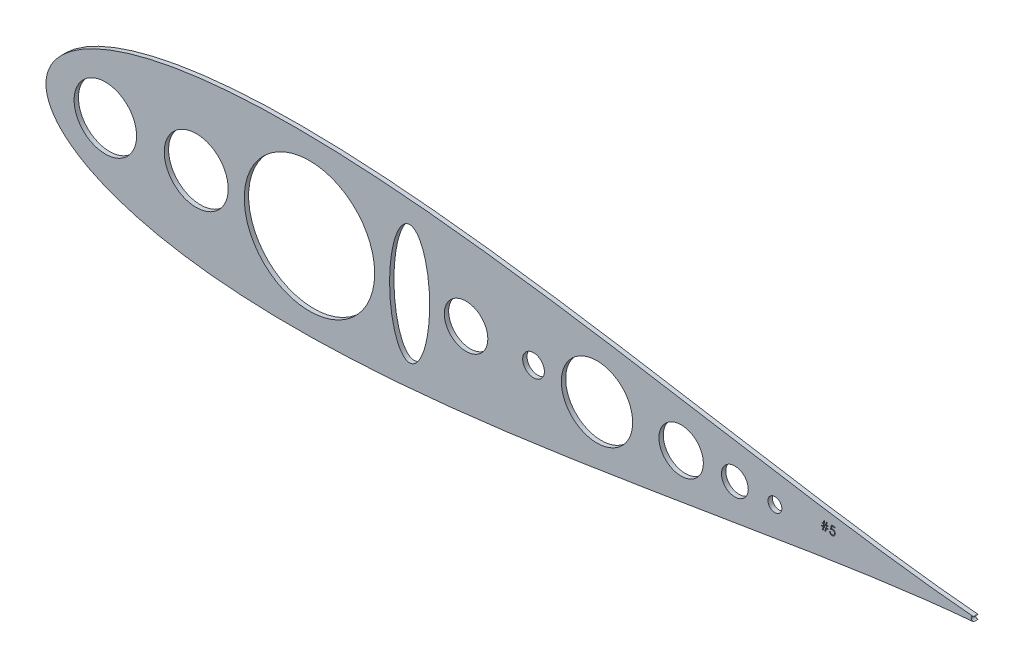
from build123d import *

# Parameters (mm, degrees)
SKETCH2_R           = 18.230878517
SKETCH2_R_2         = 4.037715602
SKETCH2_R_3         = 7.821827667
SKETCH2_R_4         = 12.957792122
SKETCH2_R_5         = 20.813476486
SKETCH2_R_6         = 6.35
SKETCH2_R_7         = 12.7
SKETCH2_R_8         = 38.053042593
SKETCH2_R_9         = 18.669
SKETCH2_RX          = 34.947973864
SKETCH2_RY          = 11.708179647
BOSS_EXTRUDE1_DEPTH = 2.54


with BuildPart() as part:
    # Sketch2 → Boss-Extrude1 (new body)
    with BuildSketch(Plane.XY):
        with BuildLine():
            ThreePointArc((823.421189551, 522.33997147), (821.998097763, 521.109243266), (823.419197676, 519.876215617))
            ThreePointArc((823.419197676, 519.876215617), (823.21960738, 519.810273255), (823.012147201, 519.776436063))
            add(Edge.make_bspline(
                [(823.012147201, 522.440589928), (822.576448471, 522.476822469), (819.292931445, 522.753399073), (812.826446411, 523.351083584), (803.227904679, 524.349584583), (792.585752436, 525.574842202), (780.939994867, 527.03420159), (768.344964456, 528.729148634), (754.855128067, 530.655883322), (740.528901562, 532.804453244), (725.427121068, 535.159573872), (709.613054207, 537.700217018), (693.152054171, 540.400141328), (676.111369741, 543.228220161), (658.559927393, 546.148757256), (640.568215799, 549.122125908), (622.208169894, 552.105244697), (603.553110232, 555.052283691), (584.67770325, 557.91528213), (565.657958282, 560.644999757), (546.571218667, 563.191541558), (527.496180515, 565.505247095), (508.512905779, 567.53740425), (489.702834491, 569.241109422), (471.148776984, 570.57195173), (452.934912277, 571.48884347), (435.146769771, 571.95479317), (417.871200148, 571.937494433), (401.196404591, 571.409505282), (385.211936158, 570.350153322), (370.008960014, 568.744076909), (355.6803978, 566.584036436), (342.32179621, 563.869274185), (330.031975696, 560.608874259), (318.914834654, 556.82194507), (309.081277399, 552.54222879), (300.650720518, 547.826398394), (293.749112715, 542.770151991), (288.492669192, 537.538633824), (284.933972909, 532.40845142), (282.949544686, 527.780006902), (282.14819506, 524.067129748), (281.965680463, 521.108512998), (282.14819506, 518.149896248), (282.949544686, 514.437019094), (284.933972909, 509.808574576), (288.492669192, 504.678392172), (293.749112715, 499.446874005), (300.650720518, 494.390627603), (309.081277399, 489.674797206), (318.914834654, 485.395080927), (330.031975696, 481.608151737), (342.32179621, 478.347751812), (355.6803978, 475.632989561), (370.008960014, 473.472949087), (385.211936158, 471.866872675), (401.196404591, 470.807520714), (417.871200148, 470.279531563), (435.146769771, 470.262232827), (452.934912277, 470.728182527), (471.148776984, 471.645074266), (489.702834491, 472.975916574), (508.512905779, 474.679621746), (527.496180515, 476.711778902), (546.571218667, 479.025484439), (565.657958282, 481.57202624), (584.67770325, 484.301743866), (603.553110232, 487.164742305), (622.208169894, 490.111781299), (640.568215799, 493.094900089), (658.559927393, 496.068268741), (676.111369741, 498.988805836), (693.152054171, 501.816884668), (709.613054207, 504.516808978), (725.427121068, 507.057452124), (740.528901562, 509.412572753), (754.855128067, 511.561142674), (768.344964456, 513.487877362), (780.939994867, 515.182824406), (792.585752436, 516.642183794), (803.227904679, 517.867441413), (812.826446411, 518.865942413), (819.292931445, 519.463626923), (822.576448471, 519.740203527), (823.012147201, 519.776436063)],
                knots=[0.020157042, 0.020157042, 0.020157042, 0.020157042, 0.021270888, 0.028552555, 0.036780684, 0.045920102, 0.055931764, 0.066772884, 0.07839713, 0.090754827, 0.103793165, 0.117456432, 0.131686226, 0.146421738, 0.161599998, 0.177156133, 0.193023668, 0.209134786, 0.225420633, 0.241811602, 0.258237647, 0.274628557, 0.290914287, 0.307025229, 0.322892517, 0.338448342, 0.353626207, 0.368361232, 0.382590428, 0.396252961, 0.409290412, 0.42164701, 0.433269881, 0.444109249, 0.45411864, 0.463255055, 0.471479114, 0.478755289, 0.485052318, 0.490344026, 0.494609833, 0.497833231, 0.5, 0.502166769, 0.505390167, 0.509655974, 0.514947682, 0.521244711, 0.528520886, 0.536744945, 0.54588136, 0.555890751, 0.566730119, 0.57835299, 0.590709588, 0.603747039, 0.617409572, 0.631638768, 0.646373793, 0.661551658, 0.677107483, 0.692974771, 0.709085713, 0.725371443, 0.741762353, 0.758188398, 0.774579367, 0.790865214, 0.806976332, 0.822843867, 0.838400002, 0.853578262, 0.868313774, 0.882543568, 0.896206835, 0.909245173, 0.92160287, 0.933227116, 0.944068236, 0.954079898, 0.963219316, 0.971447445, 0.978729112, 0.979842958, 0.979842958, 0.979842958, 0.979842958], degree=3))
            ThreePointArc((823.012147201, 522.440589928), (823.220656864, 522.406495028), (823.421189551, 522.33997147))
        make_face()
        with Locations((316.649549722, 521.108512996)):
            Circle(SKETCH2_R, mode=Mode.SUBTRACT)
        with Locations((707.419787474, 521.108512996)):
            Circle(SKETCH2_R_2, mode=Mode.SUBTRACT)
        with Locations((684.057814925, 521.108512996)):
            Circle(SKETCH2_R_3, mode=Mode.SUBTRACT)
        with Locations((652.702073206, 521.108512996)):
            Circle(SKETCH2_R_4, mode=Mode.SUBTRACT)
        with Locations((603.597568947, 521.108512996)):
            Circle(SKETCH2_R_5, mode=Mode.SUBTRACT)
        with Locations((566.553892107, 521.108512996)):
            Circle(SKETCH2_R_6, mode=Mode.SUBTRACT)
        with Locations((527.183892107, 521.108512996)):
            Circle(SKETCH2_R_7, mode=Mode.SUBTRACT)
        with Locations((435.793825307, 521.108512996)):
            Circle(SKETCH2_R_8, mode=Mode.SUBTRACT)
        with Locations((369.703892107, 521.108512996)):
            Circle(SKETCH2_R_9, mode=Mode.SUBTRACT)
        with Locations(Location((494.242570629, 521.108512996), (0, 0, -90))):
            Ellipse(SKETCH2_RX, SKETCH2_RY, mode=Mode.SUBTRACT)
        Polygon((738.293466219, 524.339836845), (738.293466219, 524.01419582), (737.322648908, 524.01419582), (737.059083207, 522.255734282), (736.665261094, 522.255734282), (736.928826795, 524.01419582), (735.889828395, 524.01419582), (735.626262694, 522.255734282), (735.232440581, 522.255734282), (735.496006282, 524.01419582), (734.646286732, 524.01419582), (734.646286732, 524.339836845), (735.544852433, 524.339836845), (735.720902119, 525.512144534), (734.776543144, 525.512144534), (734.776543144, 525.837785559), (735.76974827, 525.837785559), (736.013979044, 527.465990684), (736.406783531, 527.465990684), (736.162552757, 525.837785559), (737.202568782, 525.837785559), (737.446799556, 527.465990684), (737.839604044, 527.465990684), (737.59537327, 525.837785559), (738.423722631, 525.837785559), (738.423722631, 525.512144534), (737.546527119, 525.512144534), (737.371495069, 524.339836845), align=None, mode=Mode.SUBTRACT)
        Polygon((742.461671345, 527.335734282), (742.461671345, 526.814708634), (740.733738657, 526.814708634), (740.459996669, 525.478562808), (740.621799556, 525.521303184), (740.775461408, 525.552849659), (740.920982244, 525.571166971), (741.058362056, 525.577272745), (741.228305958, 525.570149345), (741.391126471, 525.547761521), (741.545805958, 525.511126908), (741.693362056, 525.460245496), (741.832777119, 525.395117295), (741.964051157, 525.314724659), (742.088201795, 525.220085245), (742.205229044, 525.110181396), (742.31106237, 524.989083634), (742.402648908, 524.860862483), (742.481006282, 524.723482672), (742.544099232, 524.578979471), (742.593963008, 524.425317609), (742.62856237, 524.263514722), (742.649932569, 524.09357082), (742.657055958, 523.915485883), (742.652985445, 523.791335245), (742.642809169, 523.669219858), (742.624491858, 523.550157358), (742.599051157, 523.433130109), (742.566487056, 523.319155757), (742.526799556, 523.208234282), (742.478971031, 523.099348059), (742.425036732, 522.992497096), (742.364996669, 522.890734282), (742.298850832, 522.795077222), (742.228634483, 522.705525946), (742.153329996, 522.622080433), (742.071919744, 522.544740684), (741.985421345, 522.47350671), (741.894852433, 522.408378509), (741.798177757, 522.349356071), (741.697432569, 522.296439408), (741.592616858, 522.25166377), (741.48474827, 522.212993896), (741.372809169, 522.181447421), (741.256799556, 522.157024345), (741.13671942, 522.139724659), (741.012568782, 522.128530757), (740.885365257, 522.12547787), (740.733738657, 522.131583634), (740.58821782, 522.150918571), (740.448802757, 522.181447421), (740.315493458, 522.225205433), (740.188289933, 522.281174983), (740.067192182, 522.350373697), (739.951182569, 522.430766333), (739.842296345, 522.524388122), (739.741551157, 522.628186197), (739.65199987, 522.739107672), (739.57262487, 522.857152546), (739.503426157, 522.983338446), (739.445421345, 523.115630109), (739.398610445, 523.256062808), (739.361975832, 523.403618896), (739.335517496, 523.558298383), (739.791414933, 523.558298383), (739.828049556, 523.413795172), (739.874860445, 523.284556396), (739.932865257, 523.168546782), (740.001046345, 523.066783958), (740.081438971, 522.977232672), (740.174043144, 522.896840046), (740.278858845, 522.824588446), (740.395886094, 522.762513122), (740.520036732, 522.71163171), (740.648257883, 522.676014722), (740.778514295, 522.653626908), (740.911823594, 522.646503509), (741.042079996, 522.652609282), (741.16724827, 522.669908958), (741.288346031, 522.698402546), (741.404355644, 522.739107672), (741.515277119, 522.789989084), (741.622128081, 522.854099659), (741.723890895, 522.928386521), (741.821583207, 523.014884921), (741.910116858, 523.109524345), (741.987456606, 523.210269534), (742.052584807, 523.317120496), (742.106519106, 523.429059596), (742.148241858, 523.547104471), (742.177753081, 523.670237483), (742.195052757, 523.79947627), (742.201158531, 523.93482082), (742.196070383, 524.056936197), (742.180805958, 524.17294582), (742.154347631, 524.282849659), (742.117713008, 524.386647745), (742.070902119, 524.485357672), (742.013914933, 524.577961845), (741.945733845, 524.664460245), (741.867376471, 524.74485287), (741.780878081, 524.818122096), (741.686238657, 524.881215046), (741.585493458, 524.93413171), (741.47762487, 524.978907358), (741.362632883, 525.012489084), (741.240517496, 525.036912159), (741.112296345, 525.051158958), (740.975934169, 525.056247096), (740.857889295, 525.052176584), (740.732721031, 525.039965046), (740.602464619, 525.019612483), (740.465084807, 524.991118896), (740.322616858, 524.954484282), (740.173025508, 524.909708634), (740.018346031, 524.856791971), (739.856543144, 524.795734282), (740.377568782, 527.335734282), align=None, mode=Mode.SUBTRACT)
    extrude(amount=BOSS_EXTRUDE1_DEPTH)


solid = part.part
